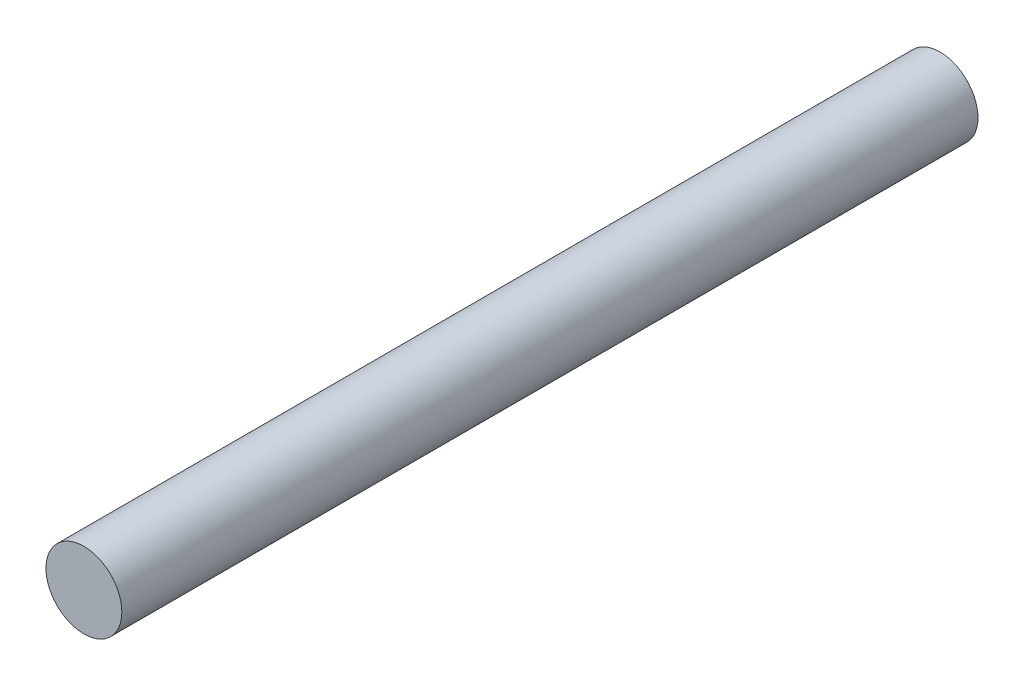
from build123d import *

# Parameters (mm, degrees)
CROQUIS11_R                  = 0.665
SALIENTE_EXTRUIR8_DEPTH      = 10
SALIENTE_EXTRUIR8_DEPTH_BACK = 5


with BuildPart() as part:
    # Croquis11 → Saliente-Extruir8 (new body, two sides)
    with BuildSketch(Plane.XY) as saliente_extruir8_sk:
        with Locations((58.498821663, 28.89344742)):
            Circle(CROQUIS11_R)
    extrude(amount=SALIENTE_EXTRUIR8_DEPTH)
    extrude(saliente_extruir8_sk.sketch, amount=-SALIENTE_EXTRUIR8_DEPTH_BACK)


solid = part.part
